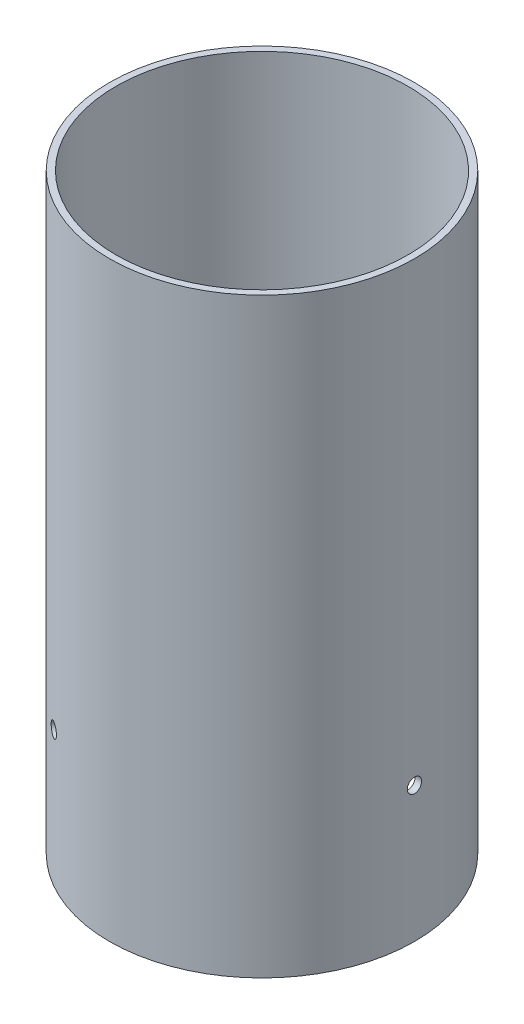
from build123d import *

# Parameters (mm, degrees)
SKETCH1_R           = 38.1381
SKETCH1_R_2         = 36.5125
BOSS_EXTRUDE1_DEPTH = 147.8153
CUT_EXTRUDE1_START  = -1.669304
SKETCH2_R           = 1.7859375
CUT_EXTRUDE1_DEPTH  = 1.669304
CIRPATTERN1_COUNT   = 3


with BuildPart() as part:
    # Sketch1 → Boss-Extrude1 (new body)
    with BuildSketch(Plane(origin=(0, 0, 0), x_dir=(1, 0, 0), z_dir=(0, 1, 0))):
        Circle(SKETCH1_R)
        Circle(SKETCH1_R_2, mode=Mode.SUBTRACT)
    extrude(amount=BOSS_EXTRUDE1_DEPTH)

    # Sketch2 → Cut-Extrude1 (cut)
    with BuildSketch(Plane(origin=(38.1381, 0, 0), x_dir=(0, 0, -1), z_dir=(1, 0, 0)).offset(CUT_EXTRUDE1_START)):
        with Locations((0, 33.8074)):
            Circle(SKETCH2_R)
    cut_extrude1 = extrude(amount=CUT_EXTRUDE1_DEPTH, mode=Mode.SUBTRACT)

    # CirPattern1: Cut-Extrude1 ×3 about axis
    cirpattern1_axis = Axis((0, 155.08605, 0), (0, -1, 0))
    for i in range(1, CIRPATTERN1_COUNT):
        add(cut_extrude1.rotate(cirpattern1_axis, i * 360 / CIRPATTERN1_COUNT), mode=Mode.SUBTRACT)


solid = part.part
